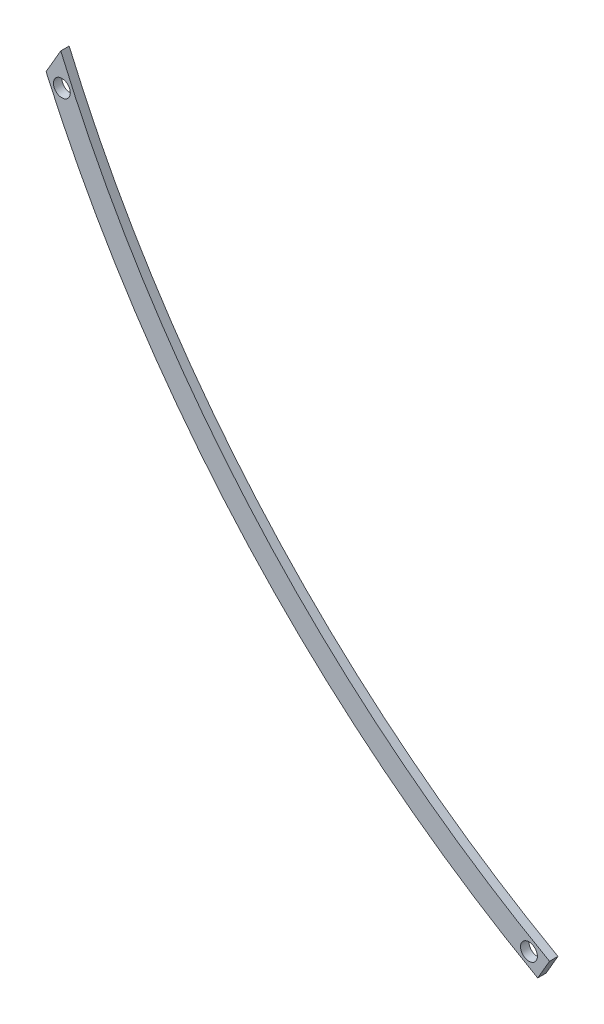
from build123d import *

# Parameters (mm, degrees)
SKETCH1_R           = 50
BOSS_EXTRUDE1_DEPTH = 50


with BuildPart() as part:
    # Sketch1 → Boss-Extrude1 (new body)
    with BuildSketch(Plane.XY):
        with BuildLine():
            Line((51.763184367, -110.08745726), (121.994454448, 11.039769792))
            ThreePointArc((121.994454448, 11.039769792), (78.46121296, 35.637111971), (35.111840631, 60.557069344))
            ThreePointArc((35.111840631, 60.557069344), (-1571.499313179, 1358.21707482), (-2709.206276596, 3081.801640413))
            ThreePointArc((-2709.206276596, 3081.801640413), (-2744.849339403, 3160.975804045), (-2779.468441107, 3240.603022447))
            Line((-2779.468441107, 3240.603022447), (-2866.636082239, 3090.265791655))
            ThreePointArc((-2866.636082239, 3090.265791655), (-2851.653572761, 3056.847211293), (-2836.493201427, 3023.508941323))
            ThreePointArc((-2836.493201427, 3023.508941323), (-1675.129633057, 1264.085481813), (-35.111840631, -60.557069343))
            ThreePointArc((-35.111840631, -60.557069343), (8.235586311, -85.480271048), (51.763184367, -110.08745726))
        make_face()
        with Locations((-2772.849739011, 3052.655290868)):
            Circle(SKETCH1_R, mode=Mode.SUBTRACT)
        Circle(SKETCH1_R, mode=Mode.SUBTRACT)
    extrude(amount=BOSS_EXTRUDE1_DEPTH)


solid = part.part
